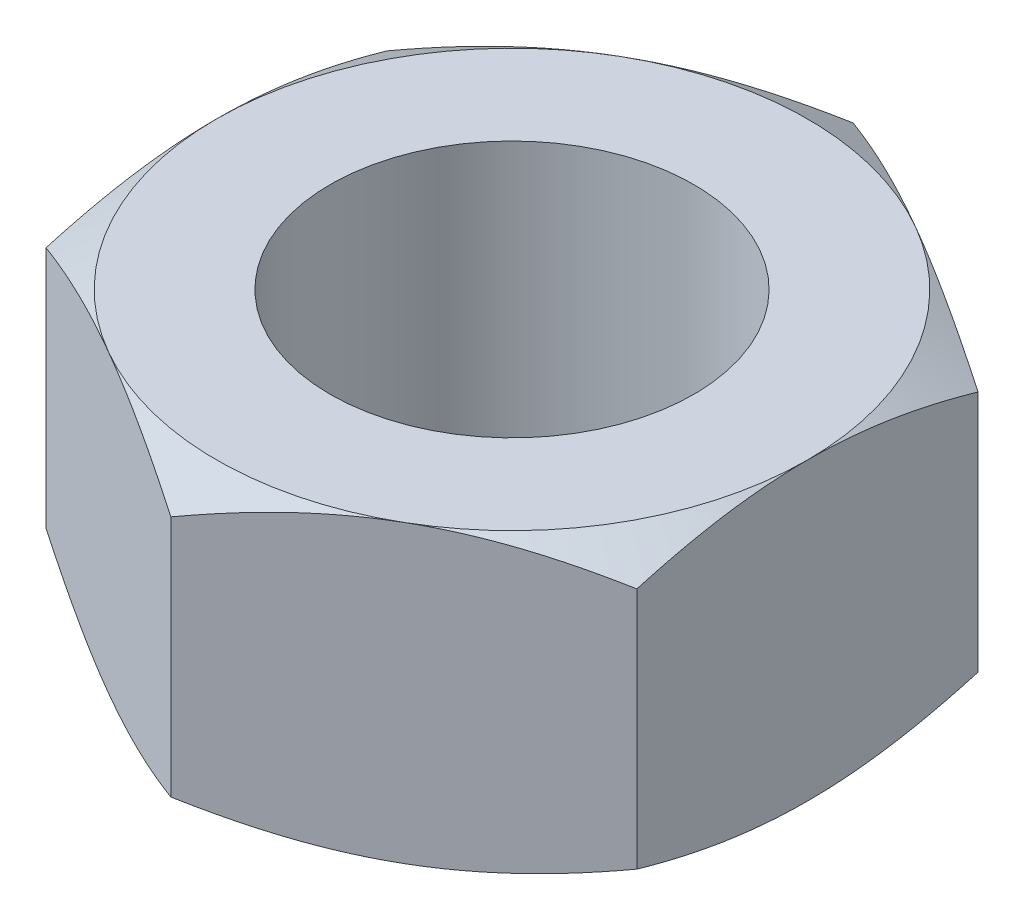
from build123d import *

# Parameters (mm, degrees)
SKETCH1_R           = 4
BOSS_EXTRUDE1_DEPTH = 3.25
SKETCH5_OUTSIDE_W   = 45.16
SKETCH5_OUTSIDE_H   = 47.172
SKETCH5_OUTSIDE_R   = 6.5
CUT_EXTRUDE2_DEPTH  = 7.5
CUT_EXTRUDE2_TAPER  = 60


with BuildPart() as part:
    # Sketch1 → Boss-Extrude1 (new body, symmetric)
    with BuildSketch(Plane(origin=(0, 0, 0), x_dir=(1, 0, 0), z_dir=(0, 1, 0))):
        Polygon((-6.5, 3.75277675), (-6.5, -3.75277675), (0, -7.505553499), (6.5, -3.75277675), (6.5, 3.75277675), (0, 7.505553499), align=None)
        Circle(SKETCH1_R, mode=Mode.SUBTRACT)
    extrude(amount=BOSS_EXTRUDE1_DEPTH, both=True)

    # Sketch5 outside → Cut-Extrude2 (cut, through all)
    with BuildSketch(Plane(origin=(0, 3.25, 0), x_dir=(1, 0, 0), z_dir=(0, 1, 0))):
        Rectangle(SKETCH5_OUTSIDE_W, SKETCH5_OUTSIDE_H)
        Circle(SKETCH5_OUTSIDE_R, mode=Mode.SUBTRACT)
    cut_extrude2 = extrude(amount=-CUT_EXTRUDE2_DEPTH, taper=CUT_EXTRUDE2_TAPER, mode=Mode.SUBTRACT)

    # Mirror1: Cut-Extrude2 across plane
    add(cut_extrude2.mirror(Plane.ZX), mode=Mode.SUBTRACT)


solid = part.part
